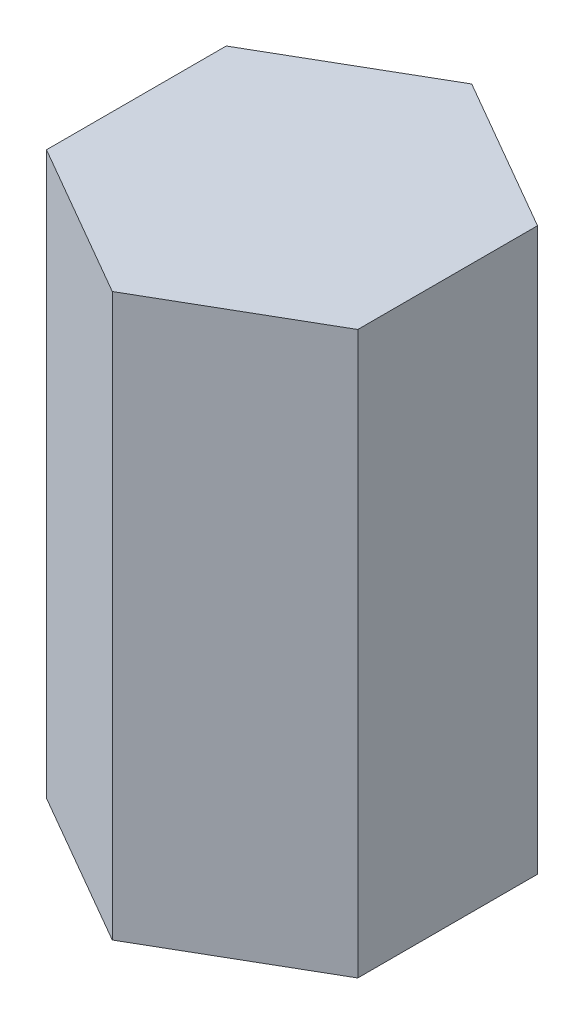
from build123d import *

# Parameters (mm, degrees)
BOSS_EXTRUDE1_DEPTH = 19.05
CUT_EXTRUDE1_DEPTH  = 10.16


with BuildPart() as part:
    # Sketch1 → Boss-Extrude1 (new body)
    # profile 1 of 2: a face of its own
    with BuildSketch(Plane(origin=(0, 0, 0), x_dir=(1, 0, 0), z_dir=(0, 1, 0))):
        Polygon((0, 6.096), (-5.279290861, 3.048), (-5.279290861, -3.048), (0, -6.096), (5.279290861, -3.048), (5.279290861, 3.048), align=None)
        with BuildLine():
            ThreePointArc((2, 1.858932557), (-2.7305, 0), (2, -1.858932557))
            Line((2, -1.858932557), (2, 1.858932557))
        make_face(mode=Mode.SUBTRACT)
    # profile 2 of 2: a face of its own
    with BuildSketch(Plane(origin=(0, 0, 0), x_dir=(1, 0, 0), z_dir=(0, 1, 0))):
        with BuildLine():
            Line((2, -1.858932557), (2, 1.858932557))
            ThreePointArc((2, 1.858932557), (-2.7305, 0), (2, -1.858932557))
        make_face()
    extrude(amount=BOSS_EXTRUDE1_DEPTH)

    # Sketch1_3 → Cut-Extrude1 (cut)
    with BuildSketch(Plane(origin=(0, 0, 0), x_dir=(1, 0, 0), z_dir=(0, 1, 0))):
        with BuildLine():
            Line((2, -1.858932557), (2, 1.858932557))
            ThreePointArc((2, 1.858932557), (-2.7305, 0), (2, -1.858932557))
        make_face()
    extrude(amount=CUT_EXTRUDE1_DEPTH, mode=Mode.SUBTRACT)


solid = part.part
